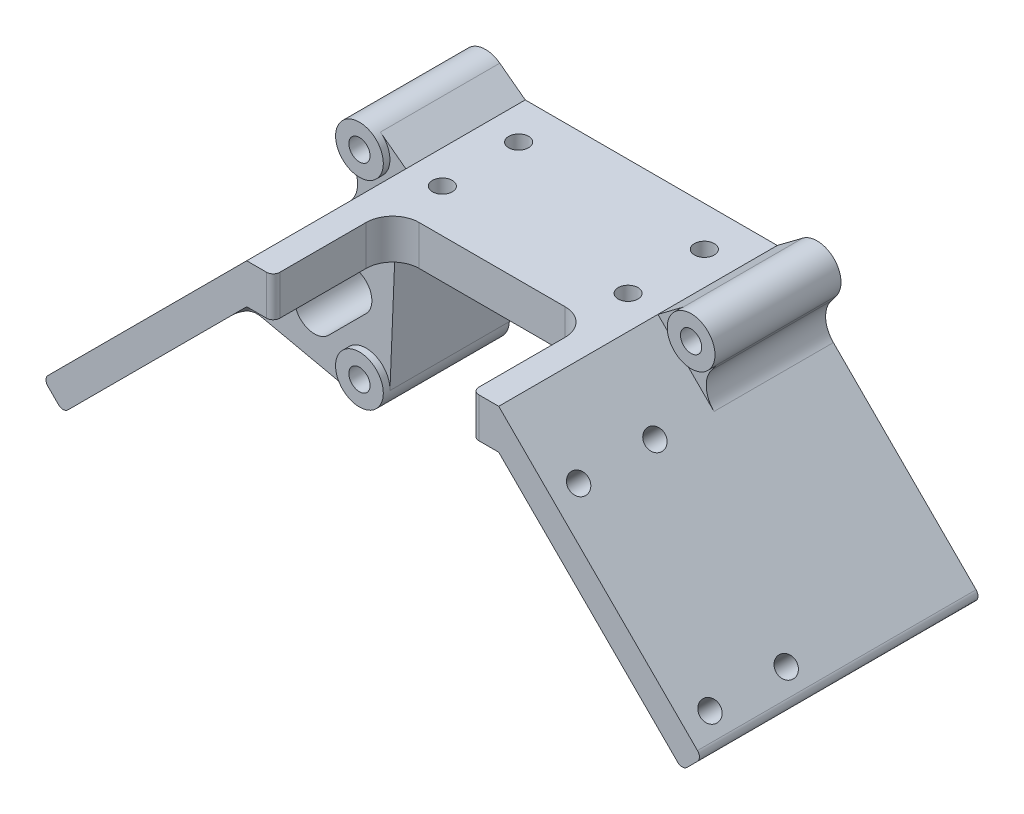
from build123d import *

# Parameters (mm, degrees)
ESQUISSE1_W             = 58
ESQUISSE1_H             = 38
ESQUISSE1_R             = 1.6
BOSS_EXTRU_1_DEPTH      = 2
BOSS_EXTRU_2_DEPTH      = 20
BOSS_EXTRU_3_DEPTH      = 20
ENL_V_MAT_EXTRU_1_DEPTH = 20
ESQUISSE6_R             = 1.5
ENL_V_MAT_EXTRU_2_DEPTH = 20
ESQUISSE7_R             = 1.5
ENL_V_MAT_EXTRU_3_DEPTH = 20
ESQUISSE8_R             = 1.5
ENL_V_MAT_EXTRU_4_DEPTH = 20
BOSS_EXTRU_5_DEPTH      = 22
ESQUISSE10_W            = 30
ESQUISSE10_H            = 18
ENL_V_MAT_EXTRU_5_DEPTH = 20
ESQUISSE11_R            = 3.6
ESQUISSE11_R_2          = 1.6
BOSS_EXTRU_6_DEPTH      = 17
BOSS_EXTRU_7_DEPTH      = 2
ESQUISSE13_R            = 1.6
BOSS_EXTRU_8_DEPTH      = 16
ENL_V_MAT_EXTRU_6_DEPTH = 16
CONG_1_R                = 4
CONG_2_R                = 1
CONG_3_R                = 1
CONG_4_R                = 1
ENL_V_MAT_EXTRU_7_DEPTH = 58.864879499


with BuildPart() as part:
    # Esquisse1 → Boss.-Extru.1 (new body)
    with BuildSketch(Plane.XY):
        Rectangle(ESQUISSE1_W, ESQUISSE1_H)
        with Locations((-25, 15)):
            Circle(ESQUISSE1_R, mode=Mode.SUBTRACT)
        with Locations((-25, -15)):
            Circle(ESQUISSE1_R, mode=Mode.SUBTRACT)
        with Locations((25, 15)):
            Circle(ESQUISSE1_R, mode=Mode.SUBTRACT)
        with Locations((25, -15)):
            Circle(ESQUISSE1_R, mode=Mode.SUBTRACT)
    extrude(amount=BOSS_EXTRU_1_DEPTH)

    # Esquisse2 → Boss.-Extru.2 (add)
    with BuildSketch(Plane.XY.offset(2)):
        Polygon((-29, -1), (-19, 9), (19, 9), (29, -1), (29, 5), (19, 15), (0, 15), (-19, 15), (-29, 5), align=None)
    extrude(amount=BOSS_EXTRU_2_DEPTH)

    # Esquisse3 → Boss.-Extru.3 (add)
    with BuildSketch(Plane.XY.offset(22)):
        Polygon((-19, 15), (-49.672555794, -15.672555794), (-46.672555794, -18.672555794), (-19, 9), (19, 9), (46.672555794, -18.672555794), (49.672555794, -15.672555794), (19, 15), align=None)
    extrude(amount=BOSS_EXTRU_3_DEPTH)

    # Esquisse4 → Enlèv. mat.-Extru.1 (cut)
    with BuildSketch(Plane.XY.offset(2)):
        with BuildLine():
            Line((-15, 9), (15, 9))
            ThreePointArc((15, 9), (19, 5), (15, 1))
            Line((15, 1), (-15, 1))
            ThreePointArc((-15, 1), (-19, 5), (-15, 9))
        make_face()
    extrude(amount=-ENL_V_MAT_EXTRU_1_DEPTH, mode=Mode.SUBTRACT)

    # Esquisse6 → Enlèv. mat.-Extru.2 (cut)
    with BuildSketch(Plane(origin=(-14, 14, 0), x_dir=(0, 0, -1), z_dir=(0.7071067811865465, -0.7071067811865487, 0))):
        with Locations(Location((-38, -42.205971521, 0), (0, 0, 90))):
            Circle(ESQUISSE6_R)
        with Locations(Location((-26.5, -14.205971521, 0), (0, 0, 90))):
            Circle(ESQUISSE6_R)
        with Locations(Location((-38, -14.205971521, 0), (0, 0, 90))):
            Circle(ESQUISSE6_R)
        with Locations(Location((-26.5, -42.205971521, 0), (0, 0, 90))):
            Circle(ESQUISSE6_R)
    extrude(amount=-ENL_V_MAT_EXTRU_2_DEPTH, mode=Mode.SUBTRACT)

    # Esquisse7 → Enlèv. mat.-Extru.3 (cut)
    with BuildSketch(Plane(origin=(14, 14, 0), x_dir=(0, 0, 1), z_dir=(-0.7071067811865464, -0.7071067811865487, 0))):
        with Locations(Location((38, -14.205971521, 0), (0, 0, 270))):
            Circle(ESQUISSE7_R)
        with Locations(Location((38, -42.205971521, 0), (0, 0, 270))):
            Circle(ESQUISSE7_R)
        with Locations(Location((26.5, -42.205971521, 0), (0, 0, 270))):
            Circle(ESQUISSE7_R)
        with Locations(Location((26.5, -14.205971521, 0), (0, 0, 270))):
            Circle(ESQUISSE7_R)
    extrude(amount=-ENL_V_MAT_EXTRU_3_DEPTH, mode=Mode.SUBTRACT)

    # Esquisse8 → Enlèv. mat.-Extru.4 (cut)
    with BuildSketch(Plane.XZ.offset(-9)):
        with Locations((-14, 17.5)):
            Circle(ESQUISSE8_R)
        with Locations((14, 17.5)):
            Circle(ESQUISSE8_R)
        with Locations((14, 6)):
            Circle(ESQUISSE8_R)
        with Locations((-14, 6)):
            Circle(ESQUISSE8_R)
    extrude(amount=-ENL_V_MAT_EXTRU_4_DEPTH, mode=Mode.SUBTRACT)

    # Esquisse9 → Boss.-Extru.5 (add)
    with BuildSketch(Plane(origin=(0, 0, 22), x_dir=(-1, 0, 0), z_dir=(0, 0, -1))):
        Polygon((49.672555794, -15.672555794), (29, 5), (29, -1), (46.672555794, -18.672555794), align=None)
        Polygon((-46.672555794, -18.672555794), (-29, -1), (-29, 5), (-49.672555794, -15.672555794), align=None)
    extrude(amount=BOSS_EXTRU_5_DEPTH)

    # Esquisse10 → Enlèv. mat.-Extru.5 (cut)
    with BuildSketch(Plane.XZ.offset(-9)):
        with Locations((0, 33)):
            Rectangle(ESQUISSE10_W, ESQUISSE10_H)
    extrude(amount=-ENL_V_MAT_EXTRU_5_DEPTH, mode=Mode.SUBTRACT)

    # Esquisse11 → Boss.-Extru.6 (add)
    with BuildSketch(Plane.XY.offset(2)):
        with Locations(Location((-25, -15, 0), (0, 0, 180))):
            Circle(ESQUISSE11_R)
        with Locations((-25, -15)):
            Circle(ESQUISSE11_R_2, mode=Mode.SUBTRACT)
        with Locations(Location((25, -15, 0), (0, 0, 180))):
            Circle(ESQUISSE11_R)
        with Locations((25, -15)):
            Circle(ESQUISSE11_R_2, mode=Mode.SUBTRACT)
        with Locations(Location((25, 15, 0), (0, 0, 180))):
            Circle(ESQUISSE11_R)
        with Locations((25, 15)):
            Circle(ESQUISSE11_R_2, mode=Mode.SUBTRACT)
        with Locations(Location((-25, 15, 0), (0, 0, 180))):
            Circle(ESQUISSE11_R)
        with Locations((-25, 15)):
            Circle(ESQUISSE11_R_2, mode=Mode.SUBTRACT)
    extrude(amount=BOSS_EXTRU_6_DEPTH)

    # Esquisse12 → Boss.-Extru.7 (add)
    with BuildSketch(Plane(origin=(0, 0, 0), x_dir=(-1, 0, 0), z_dir=(0, 0, -1))):
        Polygon((46.672555794, -18.672555794), (29, -19), (29, -1), align=None)
        Polygon((-29, -19), (-46.672555794, -18.672555794), (-29, -1), align=None)
        Polygon((29, 19), (49.672555794, -15.672555794), (29, 5), align=None)
        Polygon((-29, 19), (-29, 5), (-49.672555794, -15.672555794), align=None)
    extrude(amount=-BOSS_EXTRU_7_DEPTH)

    # Esquisse13 → Boss.-Extru.8 (add)
    with BuildSketch(Plane.XY.offset(2)):
        with BuildLine():
            ThreePointArc((-27.88, 12.84), (-27.545584412, 17.545584412), (-22.84, 17.88))
            Line((-22.84, 17.88), (-19, 15))
            Line((-19, 15), (-25, 9))
            Line((-25, 9), (-27.88, 12.84))
        make_face()
        with Locations((-25, 15)):
            Circle(ESQUISSE13_R, mode=Mode.SUBTRACT)
        with BuildLine():
            ThreePointArc((-21.4, -15), (-21.400768371, -15.07437526), (-21.403073155, -15.148718771))
            Line((-21.403073155, -15.148718771), (-20.465198865, 7.534801135))
            Line((-20.465198865, 7.534801135), (-42.785641509, -14.785641509))
            Line((-42.785641509, -14.785641509), (-25.771059191, -18.5164567))
            ThreePointArc((-25.771059191, -18.5164567), (-27.256566741, -12.195021115), (-21.4, -15))
        make_face()
        with BuildLine():
            Line((25.771059191, -18.5164567), (42.785641509, -14.785641509))
            Line((42.785641509, -14.785641509), (20.465198865, 7.534801135))
            Line((20.465198865, 7.534801135), (21.403073155, -15.148718771))
            ThreePointArc((21.403073155, -15.148718771), (24.92562474, -11.400768371), (28.6, -15))
            ThreePointArc((28.6, -15), (27.804978885, -17.256566741), (25.771059191, -18.5164567))
        make_face()
        with BuildLine():
            Line((27.88, 12.84), (25, 9))
            Line((25, 9), (19, 15))
            Line((19, 15), (22.84, 17.88))
            ThreePointArc((22.84, 17.88), (27.545584412, 17.545584412), (27.88, 12.84))
        make_face()
        with Locations((25, 15)):
            Circle(ESQUISSE13_R, mode=Mode.SUBTRACT)
    extrude(amount=BOSS_EXTRU_8_DEPTH)

    # Esquisse14 → Enlèv. mat.-Extru.6 (cut)
    with BuildSketch(Plane.XY.offset(2)):
        with BuildLine():
            Line((49.672555794, -15.672555794), (29, 19))
            Line((29, 19), (-29, 19))
            Line((-29, 19), (-49.672555794, -15.672555794))
            Line((-49.672555794, -15.672555794), (-25, 9))
            Line((-25, 9), (-27.88, 12.84))
            ThreePointArc((-27.88, 12.84), (-27.545584412, 17.545584412), (-22.84, 17.88))
            Line((-22.84, 17.88), (-19, 15))
            Line((-19, 15), (19, 15))
            Line((19, 15), (22.84, 17.88))
            ThreePointArc((22.84, 17.88), (27.545584412, 17.545584412), (27.88, 12.84))
            Line((27.88, 12.84), (25, 9))
            Line((25, 9), (49.672555794, -15.672555794))
        make_face()
        with BuildLine():
            Line((-42.785641509, -14.785641509), (-46.672555794, -18.672555794))
            Line((-46.672555794, -18.672555794), (-29, -19))
            Line((-29, -19), (29, -19))
            Line((29, -19), (46.672555794, -18.672555794))
            Line((46.672555794, -18.672555794), (42.785641509, -14.785641509))
            Line((42.785641509, -14.785641509), (25.771059191, -18.5164567))
            ThreePointArc((25.771059191, -18.5164567), (22.80186518, -17.851000405), (21.403073155, -15.148718771))
            Line((21.403073155, -15.148718771), (20.465198865, 7.534801135))
            Line((20.465198865, 7.534801135), (19, 9))
            Line((19, 9), (15, 9))
            ThreePointArc((15, 9), (19, 5), (15, 1))
            Line((15, 1), (-15, 1))
            ThreePointArc((-15, 1), (-19, 5), (-15, 9))
            Line((-15, 9), (-19, 9))
            Line((-19, 9), (-20.465198865, 7.534801135))
            Line((-20.465198865, 7.534801135), (-21.403073155, -15.148718771))
            ThreePointArc((-21.403073155, -15.148718771), (-22.80186518, -17.851000405), (-25.771059191, -18.5164567))
            Line((-25.771059191, -18.5164567), (-42.785641509, -14.785641509))
        make_face()
    extrude(amount=-ENL_V_MAT_EXTRU_6_DEPTH, mode=Mode.SUBTRACT)

    # Congé1
    cong_1_edges = [part.edges().sort_by_distance(p)[0] for p in [
        (15, 12, 24),
        (-15, 12, 24),
        (-25, 9, 9),
        (-42.785641509, -14.785641509, 9),
        (-20.465198865, 7.534801135, 9),
        (20.465198865, 7.534801135, 9),
        (42.785641509, -14.785641509, 9),
        (25, 9, 10),
    ]]
    fillet(cong_1_edges, radius=CONG_1_R)

    # Congé2
    cong_2_edges = [part.edges().sort_by_distance(p)[0] for p in [
        (-49.672555794, -15.672555794, 21),
        (-46.672555794, -18.672555794, 21),
        (46.672555794, -18.672555794, 21),
        (49.672555794, -15.672555794, 21),
    ]]
    fillet(cong_2_edges, radius=CONG_2_R)

    # Congé3
    cong_3_edges = [part.edges().sort_by_distance(p)[0] for p in [
        (15, 12, 42),
        (-15, 12, 42),
    ]]
    fillet(cong_3_edges, radius=CONG_3_R)

    # Congé4
    cong_4_edges = [part.edges().sort_by_distance(p)[0] for p in [
        (-31.847320541, -3.847320541, 18),
        (31.847320541, -3.847320541, 18),
    ]]
    fillet(cong_4_edges, radius=CONG_4_R)

    # Esquisse15 → Enlèv. mat.-Extru.7 (cut, through all)
    with BuildSketch(Plane.XY.offset(18)):
        with BuildLine():
            Line((-34.902872138, -8.3170857), (-29.246017888, -2.660231451))
            ThreePointArc((-29.246017888, -2.660231451), (-25.003377201, -2.660231451), (-25.003377201, -6.902872138))
            Line((-25.003377201, -6.902872138), (-30.660231451, -12.559726387))
            ThreePointArc((-30.660231451, -12.559726387), (-34.902872138, -12.559726387), (-34.902872138, -8.3170857))
        make_face()
        with BuildLine():
            Line((34.902872138, -8.3170857), (29.246017888, -2.660231451))
            ThreePointArc((29.246017888, -2.660231451), (25.003377201, -2.660231451), (25.003377201, -6.902872138))
            Line((25.003377201, -6.902872138), (30.660231451, -12.559726387))
            ThreePointArc((30.660231451, -12.559726387), (34.902872138, -12.559726387), (34.902872138, -8.3170857))
        make_face()
    extrude(amount=-ENL_V_MAT_EXTRU_7_DEPTH, mode=Mode.SUBTRACT)


solid = part.part
